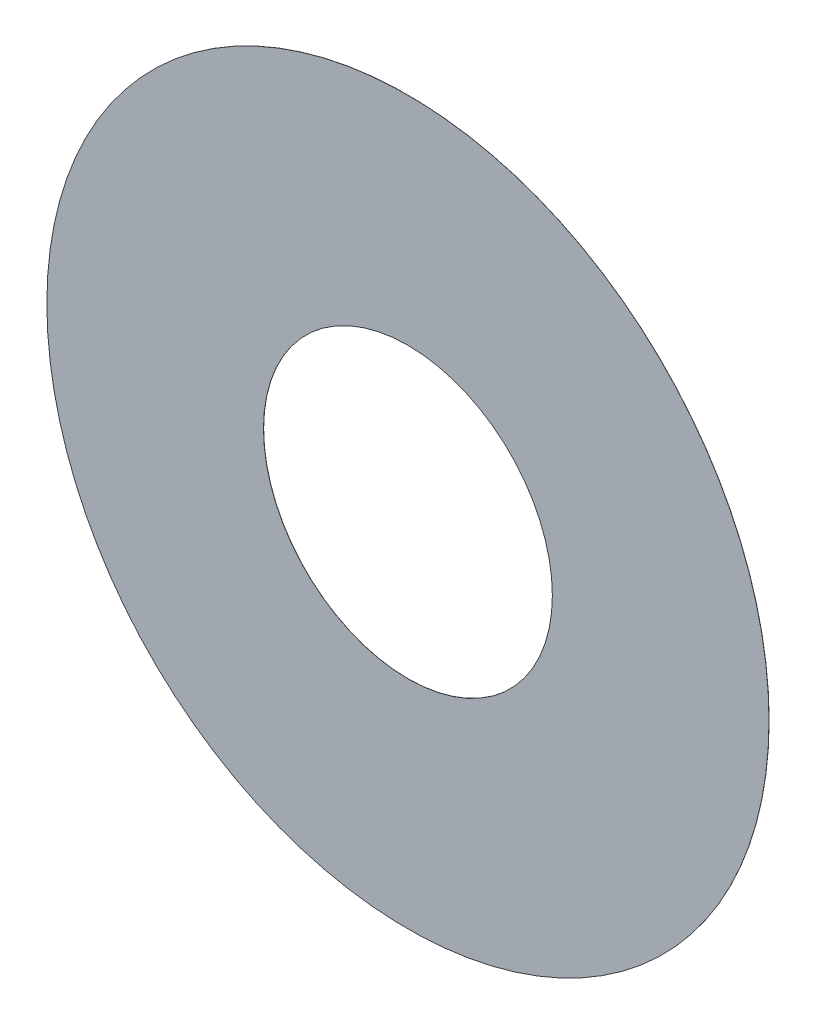
from build123d import *

# Parameters (mm, degrees)
SZKIC1_R                    = 25
SZKIC1_R_2                  = 10
DODANIE_WYCI_GNI_CIE1_DEPTH = 0.01


with BuildPart() as part:
    # Szkic1 → Dodanie-wyciągnięcie1 (new body)
    with BuildSketch(Plane.XY):
        Circle(SZKIC1_R)
        Circle(SZKIC1_R_2, mode=Mode.SUBTRACT)
    extrude(amount=DODANIE_WYCI_GNI_CIE1_DEPTH)


solid = part.part
